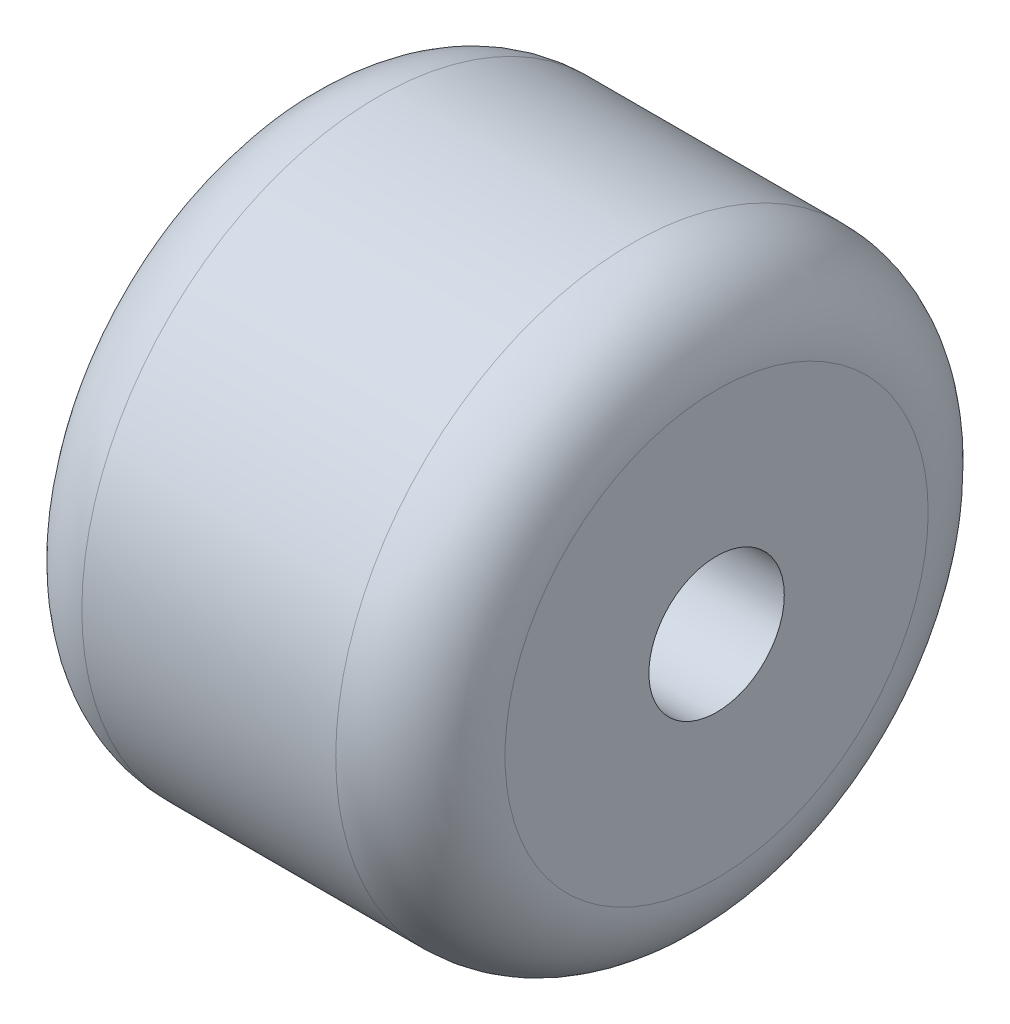
from build123d import *

# Parameters (mm, degrees)
ESQUISSE1_R        = 17.5
ESQUISSE1_R_2      = 4
BOSS_EXTRU_1_DEPTH = 25
CONG_1_R           = 5


with BuildPart() as part:
    # Esquisse1 → Boss.-Extru.1 (new body)
    with BuildSketch(Plane(origin=(0, 0, 0), x_dir=(0, 0, -1), z_dir=(1, 0, 0))):
        Circle(ESQUISSE1_R)
        Circle(ESQUISSE1_R_2, mode=Mode.SUBTRACT)
    extrude(amount=BOSS_EXTRU_1_DEPTH)

    # Congé1
    cong_1_edges = [part.edges().sort_by_distance(p)[0] for p in [
        (0, 0, 17.5),
        (25, 0, 17.5),
    ]]
    fillet(cong_1_edges, radius=CONG_1_R)


solid = part.part
